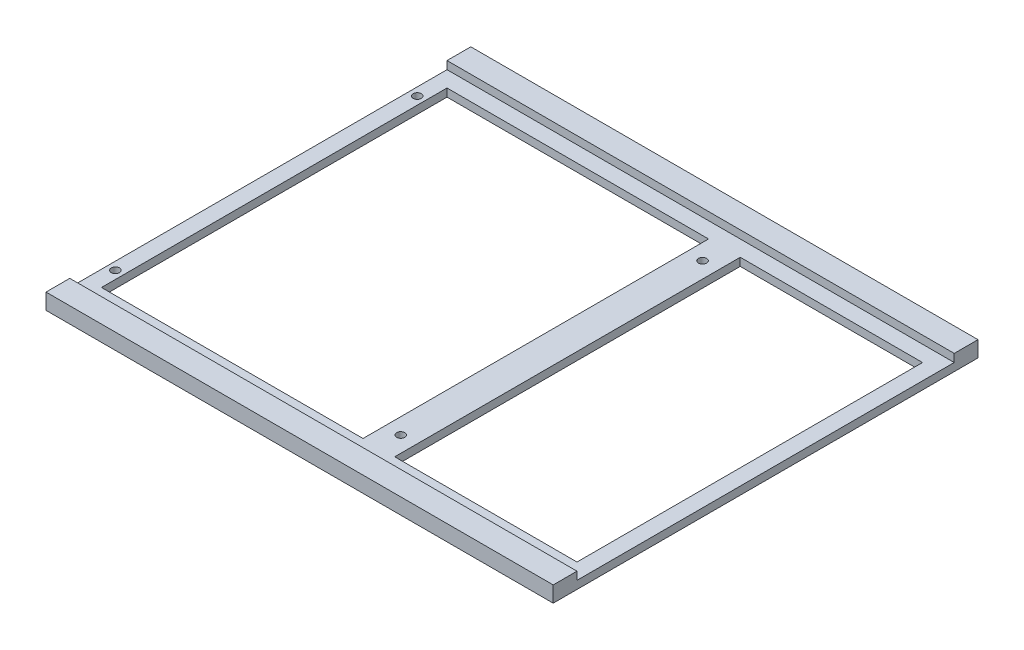
from build123d import *

# Parameters (mm, degrees)
SKETCH1_W                 = 203.2
SKETCH1_H                 = 170.18
BOSS_EXTRUDE1_DEPTH       = 6.35
SKETCH3_W                 = 151.13
SKETCH3_H                 = 3.175
CUT_EXTRUDE1_DEPTH        = 204.2
SKETCH4_W                 = 104.775
SKETCH4_H                 = 138.43
SKETCH4_W_2               = 73.025
CUT_EXTRUDE3_DEPTH        = 4.175
M4X0_7_TAPPED_HOLE1_D     = 3.3
M4X0_7_TAPPED_HOLE1_DEPTH = 9.906


with BuildPart() as part:
    # Sketch1 → Boss-Extrude1 (new body)
    with BuildSketch(Plane(origin=(0, 0, 0), x_dir=(1, 0, 0), z_dir=(0, 1, 0))):
        Rectangle(SKETCH1_W, SKETCH1_H)
    extrude(amount=BOSS_EXTRUDE1_DEPTH)

    # Sketch3 → Cut-Extrude1 (cut, through all)
    with BuildSketch(Plane(origin=(101.6, 0, 0), x_dir=(0, 0, -1), z_dir=(1, 0, 0))):
        with Locations((0, 4.7625)):
            Rectangle(SKETCH3_W, SKETCH3_H)
    extrude(amount=-CUT_EXTRUDE1_DEPTH, mode=Mode.SUBTRACT)

    # Sketch4 → Cut-Extrude3 (cut, through all)
    with BuildSketch(Plane(origin=(0, 3.175, 0), x_dir=(1, 0, 0), z_dir=(0, 1, 0))):
        with Locations((-42.8625, 0)):
            Rectangle(SKETCH4_W, SKETCH4_H)
        with Locations((58.7375, 0)):
            Rectangle(SKETCH4_W_2, SKETCH4_H)
    extrude(amount=-CUT_EXTRUDE3_DEPTH, mode=Mode.SUBTRACT)

    # M4x0.7 Tapped Hole1
    with Locations(Plane(origin=(0, 3.175, 0), x_dir=(1, 0, 0), z_dir=(0, 1, 0))):
        with Locations((-98.425, -60.452), (-98.425, 60.452), (15.875, 60.452), (15.875, -60.452)):
            Hole(M4X0_7_TAPPED_HOLE1_D / 2, depth=M4X0_7_TAPPED_HOLE1_DEPTH)


solid = part.part
